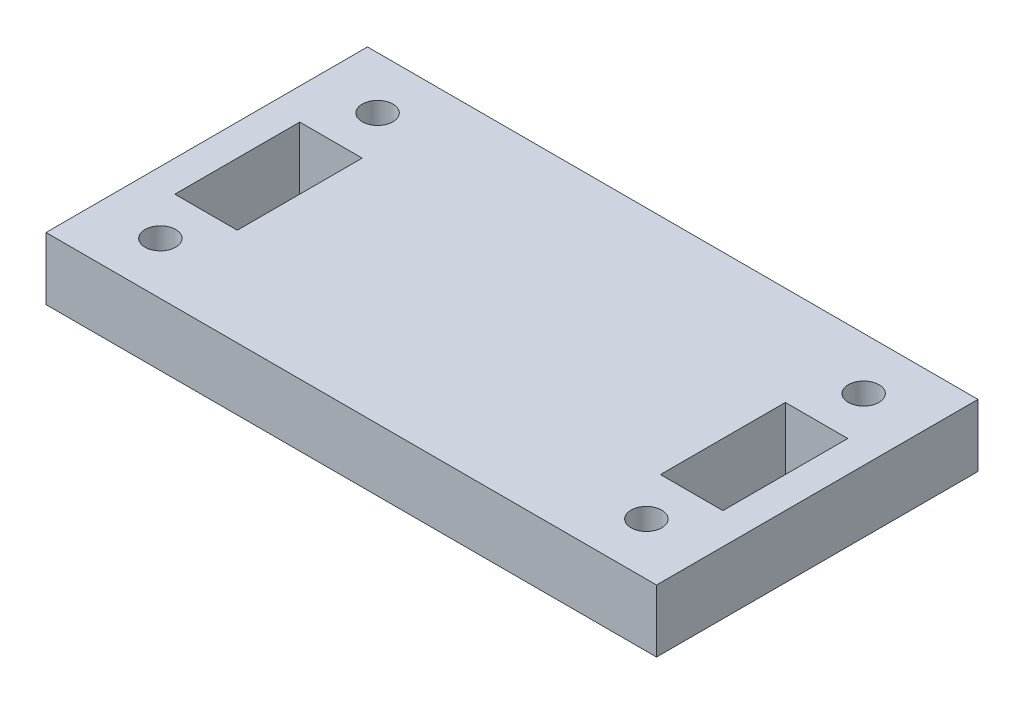
from build123d import *

# Parameters (mm, degrees)
SKETCH1_R           = 1.5621
SKETCH1_W           = 6.35
SKETCH1_H           = 12.7
BOSS_EXTRUDE1_DEPTH = 6.35


with BuildPart() as part:
    # Sketch1 → Boss-Extrude1 (new body)
    with BuildSketch(Plane(origin=(0, 0, 0), x_dir=(1, 0, 0), z_dir=(0, 1, 0))):
        Polygon((-29.684698321, 16.343647987), (29.684698321, 16.343647987), (31.0388, 16.343647987), (31.0388, -16.343647987), (29.684698321, -16.343647987), (-29.684698321, -16.343647987), (-31.0388, -16.343647987), (-31.0388, 16.343647987), align=None)
        with Locations((-24.709647151, 11.044056729)):
            Circle(SKETCH1_R, mode=Mode.SUBTRACT)
        with Locations((-24.709647151, -11.044056729)):
            Circle(SKETCH1_R, mode=Mode.SUBTRACT)
        with Locations((24.709647151, 11.044056729)):
            Circle(SKETCH1_R, mode=Mode.SUBTRACT)
        with Locations((24.709647151, -11.044056729)):
            Circle(SKETCH1_R, mode=Mode.SUBTRACT)
        with Locations((24.6888, -0.068443271)):
            Rectangle(SKETCH1_W, SKETCH1_H, mode=Mode.SUBTRACT)
        with Locations((-24.6888, -0.068443271)):
            Rectangle(SKETCH1_W, SKETCH1_H, mode=Mode.SUBTRACT)
    extrude(amount=BOSS_EXTRUDE1_DEPTH)


solid = part.part
